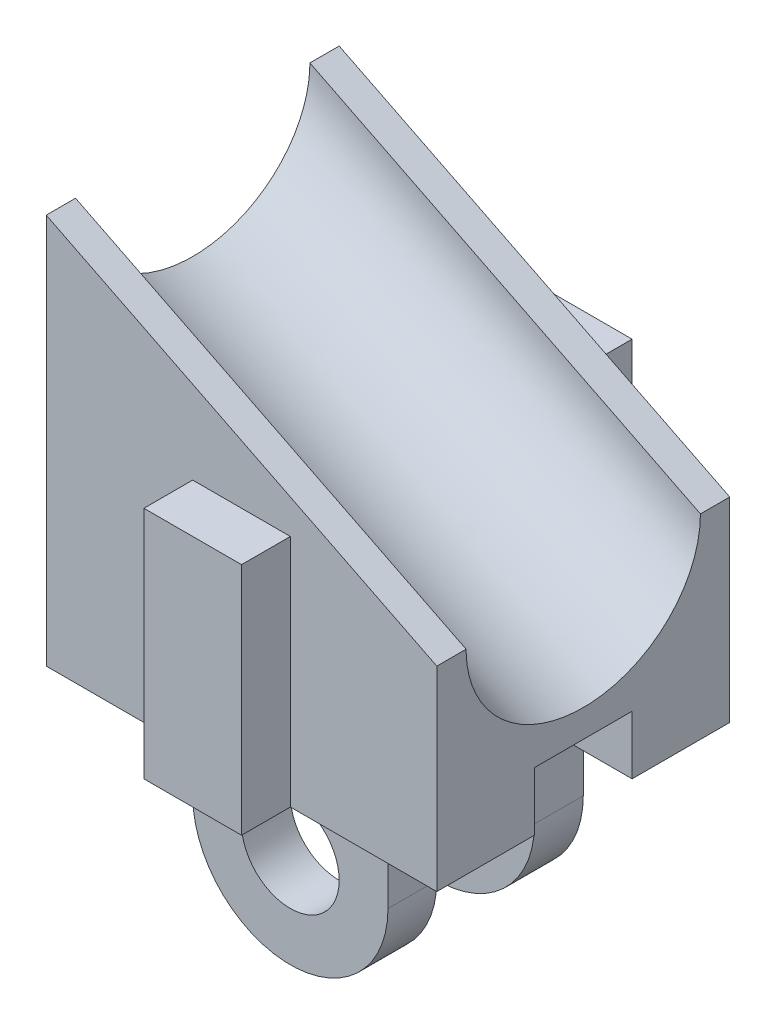
from build123d import *

# Parameters (mm, degrees)
BOSS_EXTRUDE1_DEPTH = 9.525
SKETCH3_RX          = 7.62
SKETCH3_RY          = 6.35
CUT_EXTRUDE1_DEPTH  = 35.077675977
SKETCH4_W           = 6.35
SKETCH4_H           = 15.24
BOSS_EXTRUDE2_DEPTH = 3.175
SKETCH5_R           = 3.175
BOSS_EXTRUDE3_DEPTH = 3.175
SKETCH6_W           = 6.35
SKETCH6_H           = 3.81
CUT_EXTRUDE2_DEPTH  = 19.05


with BuildPart() as part:
    # Sketch1 → Boss-Extrude1 (new body, symmetric)
    with BuildSketch(Plane.XY):
        Polygon((-12.7, 12.7), (12.7, 0), (12.7, -12.7), (-12.7, -12.7), align=None)
    extrude(amount=BOSS_EXTRUDE1_DEPTH, both=True)

    # Sketch3 → Cut-Extrude1 (cut, through all)
    with BuildSketch(Plane(origin=(-15.24, 7.62, 0), x_dir=(0, 0, -1), z_dir=(-0.894427191, 0.447213595, 0))):
        with Locations(Location((0, -5.679612663), (0, 0, 0))):
            Ellipse(SKETCH3_RX, SKETCH3_RY)
    extrude(amount=-CUT_EXTRUDE1_DEPTH, mode=Mode.SUBTRACT)

    # Sketch4 → Boss-Extrude2 (add)
    with BuildSketch(Plane.XY.offset(9.525)):
        with Locations((0, -5.08)):
            Rectangle(SKETCH4_W, SKETCH4_H)
    boss_extrude2 = extrude(amount=BOSS_EXTRUDE2_DEPTH)

    # Sketch5 → Boss-Extrude3 (add)
    with BuildSketch(Plane.XY.offset(3.175)):
        with BuildLine():
            Line((-6.35, -12.7), (-6.35, -18.415))
            ThreePointArc((-6.35, -18.415), (0, -24.765), (6.35, -18.415))
            Line((6.35, -18.415), (6.35, -12.7))
            Line((6.35, -12.7), (-6.35, -12.7))
        make_face()
        with Locations((0, -18.415)):
            Circle(SKETCH5_R, mode=Mode.SUBTRACT)
    boss_extrude3 = extrude(amount=BOSS_EXTRUDE3_DEPTH)

    # Mirror1: Boss-Extrude2, Boss-Extrude3 across plane
    add(boss_extrude2.mirror(Plane.XY))
    add(boss_extrude3.mirror(Plane.XY))

    # Sketch6 → Cut-Extrude2 (cut)
    with BuildSketch(Plane(origin=(12.7, 0, 0), x_dir=(0, 0, -1), z_dir=(1, 0, 0))):
        with Locations((0, -10.795)):
            Rectangle(SKETCH6_W, SKETCH6_H)
    extrude(amount=-CUT_EXTRUDE2_DEPTH, mode=Mode.SUBTRACT)


solid = part.part
